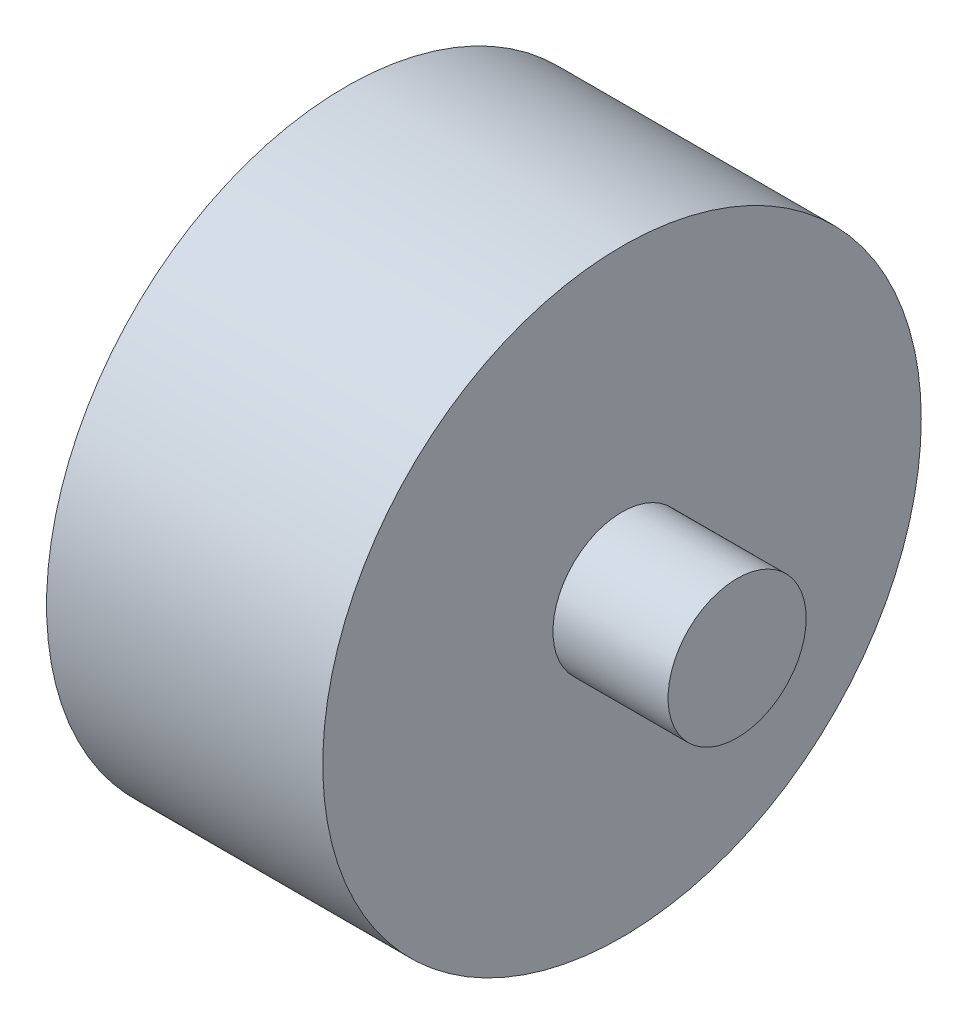
from build123d import *

# Parameters (mm, degrees)
SKETCH1_R           = 65
BOSS_EXTRUDE1_DEPTH = 60
SKETCH2_R           = 15
BOSS_EXTRUDE2_DEPTH = 25


with BuildPart() as part:
    # Sketch1 → Boss-Extrude1 (new body)
    with BuildSketch(Plane(origin=(0, 0, 0), x_dir=(0, 0, -1), z_dir=(1, 0, 0))):
        Circle(SKETCH1_R)
    extrude(amount=BOSS_EXTRUDE1_DEPTH)

    # Sketch2 → Boss-Extrude2 (add)
    with BuildSketch(Plane(origin=(60, 0, 0), x_dir=(0, 0, -1), z_dir=(1, 0, 0))):
        Circle(SKETCH2_R)
    extrude(amount=BOSS_EXTRUDE2_DEPTH)


solid = part.part
